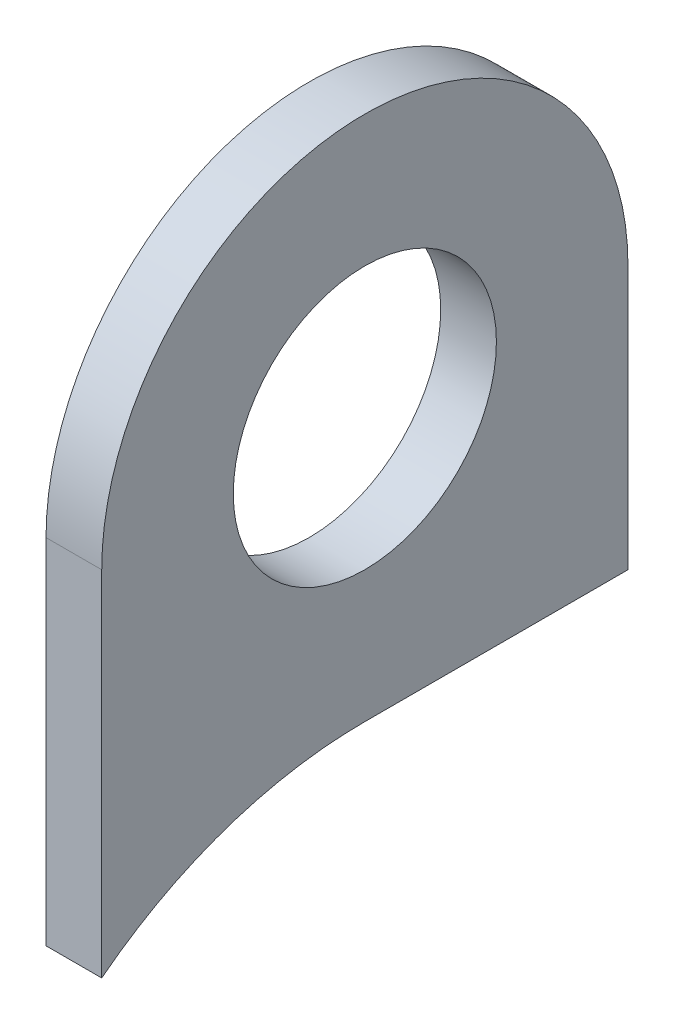
from build123d import *

# Parameters (mm, degrees)
SKETCH1_R           = 30
BOSS_EXTRUDE1_DEPTH = 6.35


with BuildPart() as part:
    # Sketch1 → Boss-Extrude1 (new body, symmetric)
    with BuildSketch(Plane(origin=(0, 0, 0), x_dir=(0, 0, -1), z_dir=(1, 0, 0))):
        with BuildLine():
            Line((60, 0), (60, 60))
            ThreePointArc((60, 60), (0, 120), (-60, 60))
            Line((-60, 60), (-60, 0))
            Line((-60, 0), (-60, -20.621041836))
            ThreePointArc((-60, -20.621041836), (-31.722339788, -5.299116156), (0, 0))
            Line((0, 0), (60, 0))
        make_face()
        with Locations((0, 60)):
            Circle(SKETCH1_R, mode=Mode.SUBTRACT)
    extrude(amount=BOSS_EXTRUDE1_DEPTH, both=True)


solid = part.part
